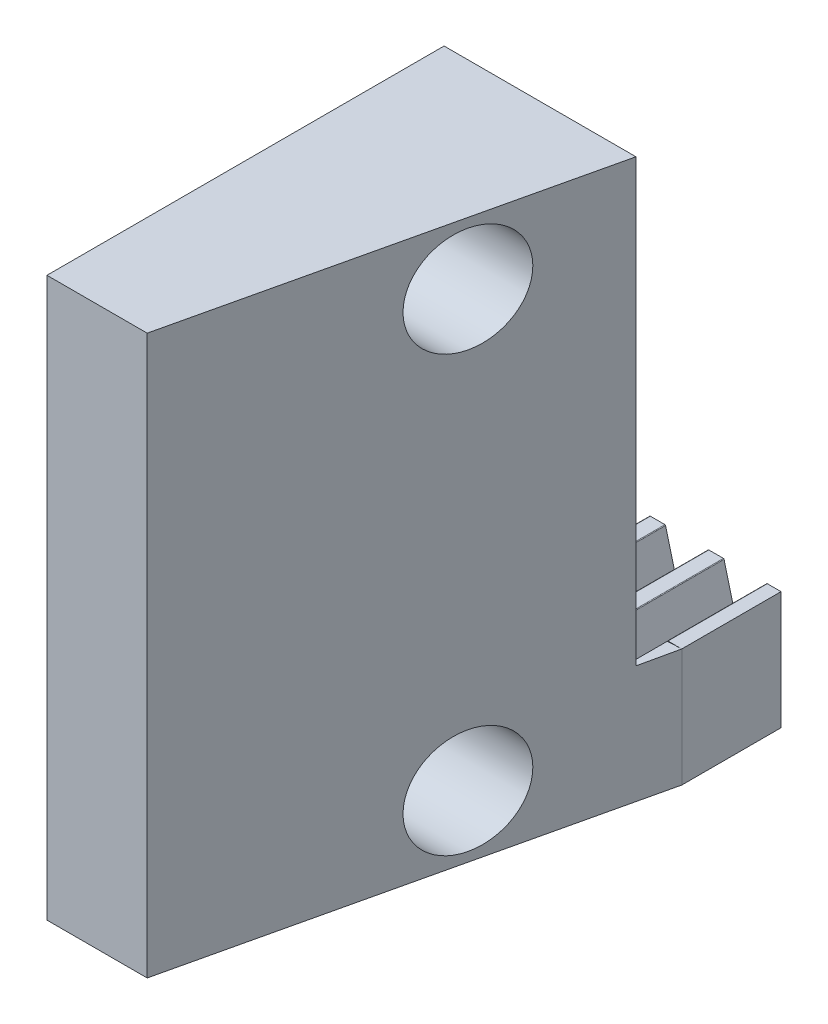
from build123d import *

# Parameters (mm, degrees)
BLANKSKE_W          = 50
BLANKSKE_H          = 9.5
BLANK_DEPTH         = 8
TOOTHCUTILL_DEPTH   = 52.519413817
TOOTHCUTSIM_DEPTH   = 52.519413817
TEETHCUTS_COUNT     = 11
TEETHCUTS_PITCH     = 4.712388975
BOSS_EXTRUDE8_DEPTH = 45
CUT_EXTRUDE5_DEPTH  = 3
SKETCH20_R          = 4.25
CUT_EXTRUDE6_DEPTH  = 25


with BuildPart() as part:
    # BlankSke → Blank (new body)
    with BuildSketch(Plane.XY):
        with Locations((25, 4.75)):
            Rectangle(BLANKSKE_W, BLANKSKE_H)
    extrude(amount=-BLANK_DEPTH)

    # TooCutSkeIll → ToothCutIll (cut, through all)
    with BuildSketch(Plane.XY):
        with BuildLine():
            Line((-1.713391726, 9.4550228), (-0.92508248, 6.406857118))
            ThreePointArc((-0.92508248, 6.406857118), (-0.791252665, 6.20370072), (-0.561058967, 6.125))
            Line((-0.561058967, 6.125), (0.561058967, 6.125))
            ThreePointArc((0.561058967, 6.125), (0.791252665, 6.20370072), (0.92508248, 6.406857118))
            Line((0.92508248, 6.406857118), (1.713391726, 9.4550228))
            ThreePointArc((1.713391726, 9.4550228), (1.734747547, 9.487441374), (1.771480584, 9.5))
            Line((1.771480584, 9.5), (1.771480584, 9.5254))
            Line((1.771480584, 9.5254), (-1.771480584, 9.5254))
            Line((-1.771480584, 9.5254), (-1.771480584, 9.5))
            ThreePointArc((-1.771480584, 9.5), (-1.734747547, 9.487441374), (-1.713391726, 9.4550228))
        make_face()
    toothcutill = extrude(amount=-TOOTHCUTILL_DEPTH, mode=Mode.SUBTRACT)

    # TooCutSkeSim → ToothCutSim (cut, through all)
    with BuildSketch(Plane.XY):
        Polygon((0.852189273, 6.125), (-0.852189273, 6.125), (-1.731592507, 9.5254), (1.731592507, 9.5254), align=None)
    toothcutsim = extrude(amount=-TOOTHCUTSIM_DEPTH, mode=Mode.SUBTRACT)

    # TeethCuts: ToothCutIll, ToothCutSim ×11
    with Locations(*[(i * TEETHCUTS_PITCH, 0, 0) for i in range(1, TEETHCUTS_COUNT)]):
        add(toothcutill, mode=Mode.SUBTRACT)
        add(toothcutsim, mode=Mode.SUBTRACT)

    # Sketch16 → Boss-Extrude8 (add)
    with BuildSketch(Plane.XZ):
        Polygon((50, 0), (33.849, 0), (33.849, 35), (41.925, 35), align=None)
    extrude(amount=-BOSS_EXTRUDE8_DEPTH)

    # Sketch17 → Cut-Extrude5 (cut)
    with BuildSketch(Plane(origin=(0, 0, 0), x_dir=(-1, 0, 0), z_dir=(0, 0, -1))):
        Polygon((-50, 9.5), (-48.837281476, 9.4550228), (-47.976079023, 6.125), (-46.271700477, 6.125), (-45.410498024, 9.4550228), (-44.124892501, 9.4550228), (-43.263690048, 6.125), (-41.559311502, 6.125), (-40.698109049, 9.4550228), (-39.412503526, 9.4550228), (-38.551301073, 6.125), (-36.846922527, 6.125), (-35.985720074, 9.4550228), (-34.700114551, 9.4550228), (-33.838912098, 6.125), (-33.849, 45), (-50, 45), align=None)
    extrude(amount=-CUT_EXTRUDE5_DEPTH, mode=Mode.SUBTRACT)

    # Sketch20 → Cut-Extrude6 (cut)
    with BuildSketch(Plane.ZY.offset(-33.849)):
        with Locations((14, 40)):
            Circle(SKETCH20_R)
        with Locations((14, 5)):
            Circle(SKETCH20_R)
    extrude(amount=-CUT_EXTRUDE6_DEPTH, mode=Mode.SUBTRACT)


solid = part.part
